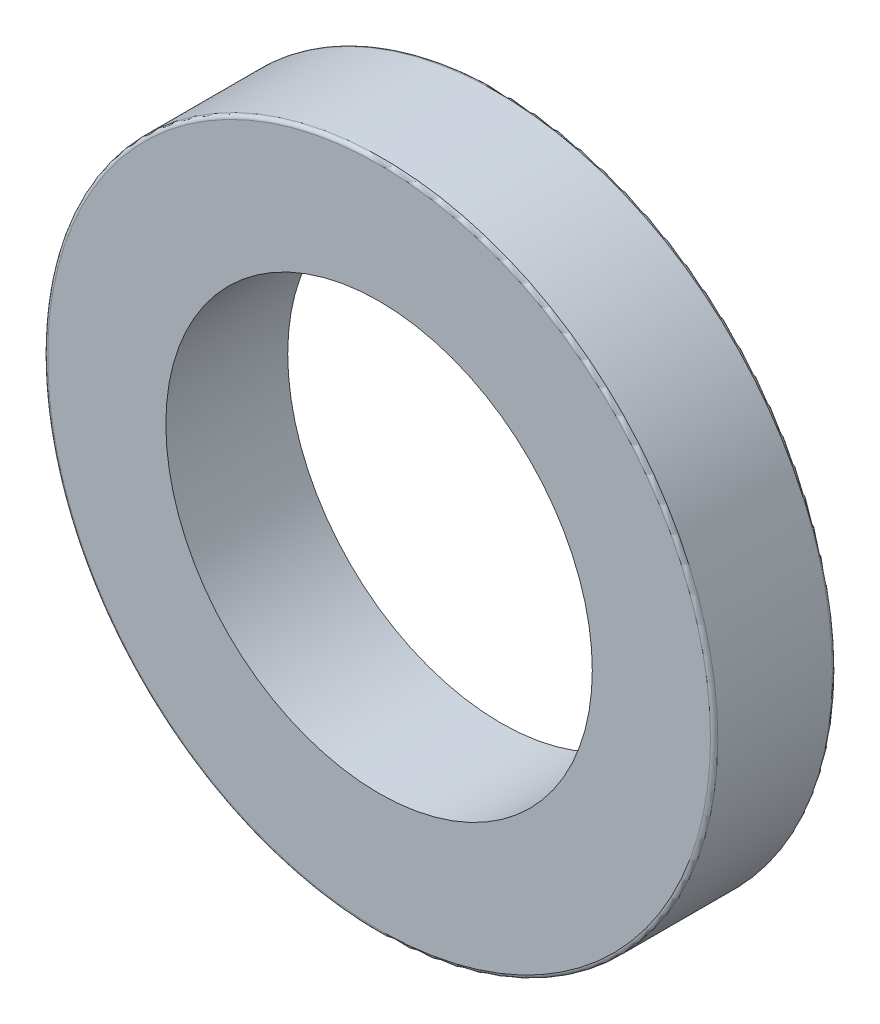
from build123d import *

# Parameters (mm, degrees)
SKETCH1_R           = 27.5
SKETCH1_R_2         = 17.5
BOSS_EXTRUDE1_DEPTH = 10
FILLET1_R           = 0.3


with BuildPart() as part:
    # Sketch1 → Boss-Extrude1 (new body)
    with BuildSketch(Plane.XY):
        Circle(SKETCH1_R)
        Circle(SKETCH1_R_2, mode=Mode.SUBTRACT)
    extrude(amount=BOSS_EXTRUDE1_DEPTH)

    # Fillet1
    fillet1_edges = [part.edges().sort_by_distance(p)[0] for p in [
        (-27.5, 0, 0),
        (-27.5, 0, 10),
    ]]
    fillet(fillet1_edges, radius=FILLET1_R)


solid = part.part
